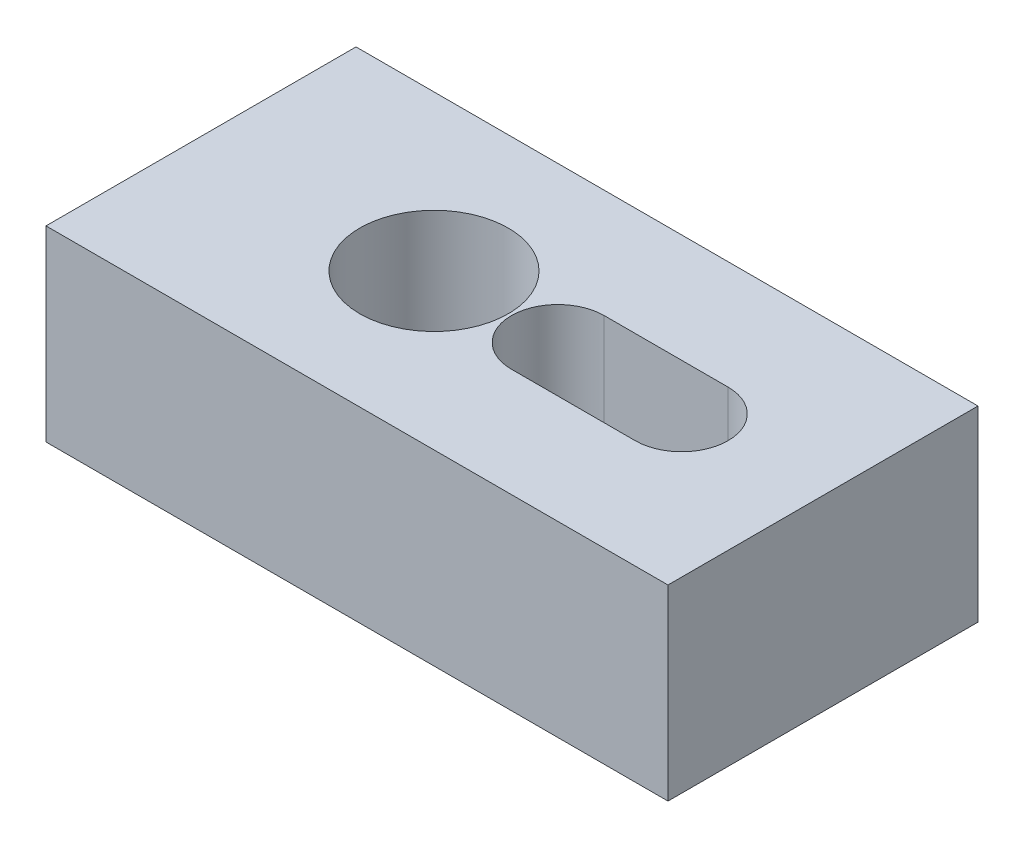
from build123d import *

# Parameters (mm, degrees)
SKETCH1_W           = 63.8
SKETCH1_H           = 31.8
SKETCH1_R           = 7.62
BOSS_EXTRUDE1_DEPTH = 19.2


with BuildPart() as part:
    # Sketch1 → Boss-Extrude1 (new body)
    with BuildSketch(Plane(origin=(0, 0, 0), x_dir=(1, 0, 0), z_dir=(0, 1, 0))):
        with Locations((-45.075543036, 45.955000213)):
            Rectangle(SKETCH1_W, SKETCH1_H)
        with Locations((-53.075543036, 45.955000213)):
            Circle(SKETCH1_R, mode=Mode.SUBTRACT)
        with BuildLine():
            Line((-40.375543036, 50.717500213), (-27.675543036, 50.717500213))
            ThreePointArc((-27.675543036, 50.717500213), (-22.913043036, 45.955000213), (-27.675543036, 41.192500213))
            Line((-27.675543036, 41.192500213), (-40.375543036, 41.192500213))
            ThreePointArc((-40.375543036, 41.192500213), (-45.138043036, 45.955000213), (-40.375543036, 50.717500213))
        make_face(mode=Mode.SUBTRACT)
    extrude(amount=BOSS_EXTRUDE1_DEPTH)


solid = part.part
